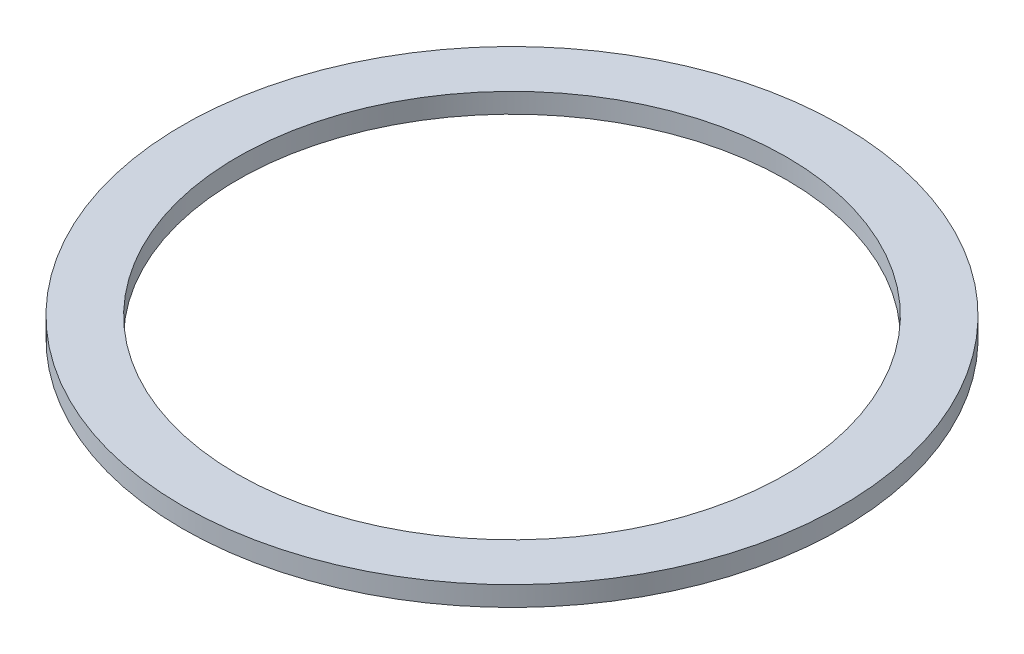
from build123d import *

# Parameters (mm, degrees)
CROQUIS1_R              = 150
CROQUIS1_R_2            = 125
SALIENTE_EXTRUIR1_DEPTH = 9


with BuildPart() as part:
    # Croquis1 → Saliente-Extruir1 (new body)
    with BuildSketch(Plane(origin=(0, 0, 0), x_dir=(1, 0, 0), z_dir=(0, 1, 0))):
        Circle(CROQUIS1_R)
        Circle(CROQUIS1_R_2, mode=Mode.SUBTRACT)
    extrude(amount=SALIENTE_EXTRUIR1_DEPTH)


solid = part.part
